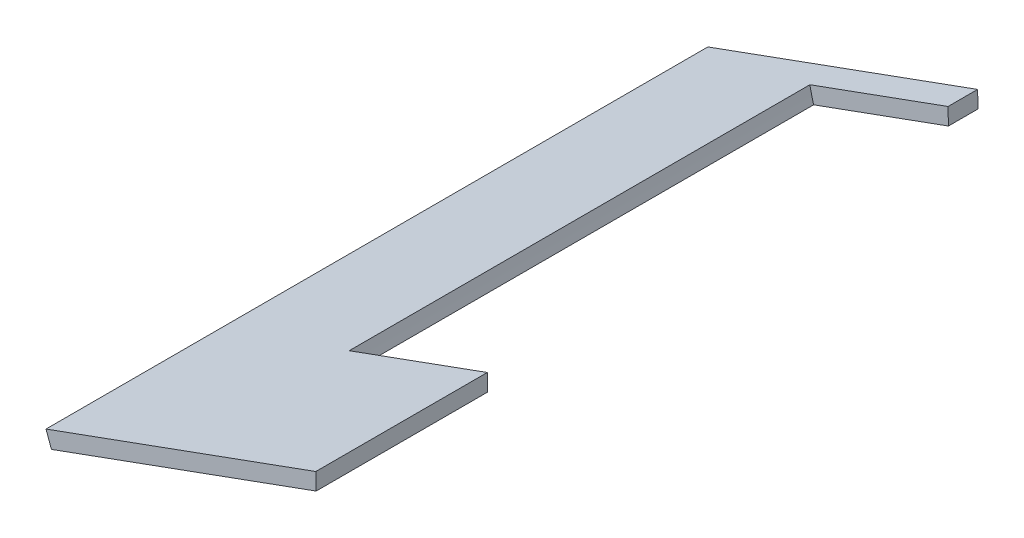
from build123d import *

# Parameters (mm, degrees)
BOSS_EXTRUDE1_DEPTH = 208.295833
SKETCH3_R           = 77.5
CUT_EXTRUDE1_DEPTH  = 145


with BuildPart() as part:
    # Sketch2 → Boss-Extrude1 (new body)
    with BuildSketch(Plane.XY.offset(2)):
        Polygon((9824.878184452, 584.852821259), (9909.787083093, 615.730562922), (9909.905272796, 610.453189538), (9826.586986697, 580.153885753), align=None)
    extrude(amount=BOSS_EXTRUDE1_DEPTH)

    # Sketch3 → Cut-Extrude1 (cut)
    with BuildSketch(Plane.XY.offset(156.31)):
        with Locations((9942.206448064, 615.592583884)):
            Circle(SKETCH3_R)
    extrude(amount=-CUT_EXTRUDE1_DEPTH, mode=Mode.SUBTRACT)


solid = part.part
